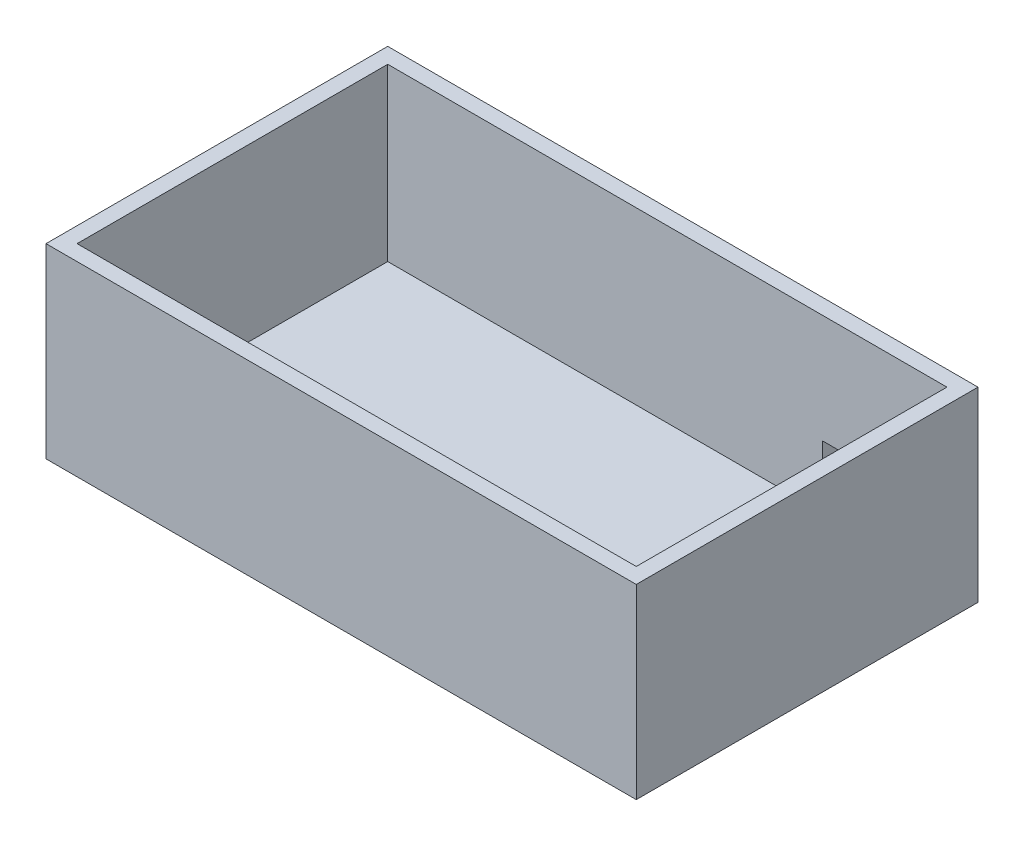
from build123d import *

# Parameters (mm, degrees)
SKETCH1_W           = 190
SKETCH1_H           = 110
SKETCH1_W_2         = 180
SKETCH1_H_2         = 100
BOSS_EXTRUDE1_DEPTH = 60
SKETCH2_W           = 110
SKETCH2_H           = 5
BOSS_EXTRUDE2_DEPTH = 190
SKETCH3_W           = 25
SKETCH3_H           = 20
CUT_EXTRUDE1_DEPTH  = 60


with BuildPart() as part:
    # Sketch1 → Boss-Extrude1 (new body)
    with BuildSketch(Plane(origin=(0, 0, 0), x_dir=(1, 0, 0), z_dir=(0, 1, 0))):
        with Locations((90, 50)):
            Rectangle(SKETCH1_W, SKETCH1_H)
        with Locations((90, 50)):
            Rectangle(SKETCH1_W_2, SKETCH1_H_2, mode=Mode.SUBTRACT)
    extrude(amount=BOSS_EXTRUDE1_DEPTH)

    # Sketch2 → Boss-Extrude2 (add)
    with BuildSketch(Plane(origin=(185, 0, 0), x_dir=(0, 0, -1), z_dir=(1, 0, 0))):
        with Locations((50, 2.5)):
            Rectangle(SKETCH2_W, SKETCH2_H)
    extrude(amount=-BOSS_EXTRUDE2_DEPTH)

    # Sketch3 → Cut-Extrude1 (cut)
    with BuildSketch(Plane(origin=(0, 0, -105), x_dir=(-1, 0, 0), z_dir=(0, 0, -1))):
        with Locations((-152.5, 15)):
            Rectangle(SKETCH3_W, SKETCH3_H)
    extrude(amount=-CUT_EXTRUDE1_DEPTH, mode=Mode.SUBTRACT)


solid = part.part
